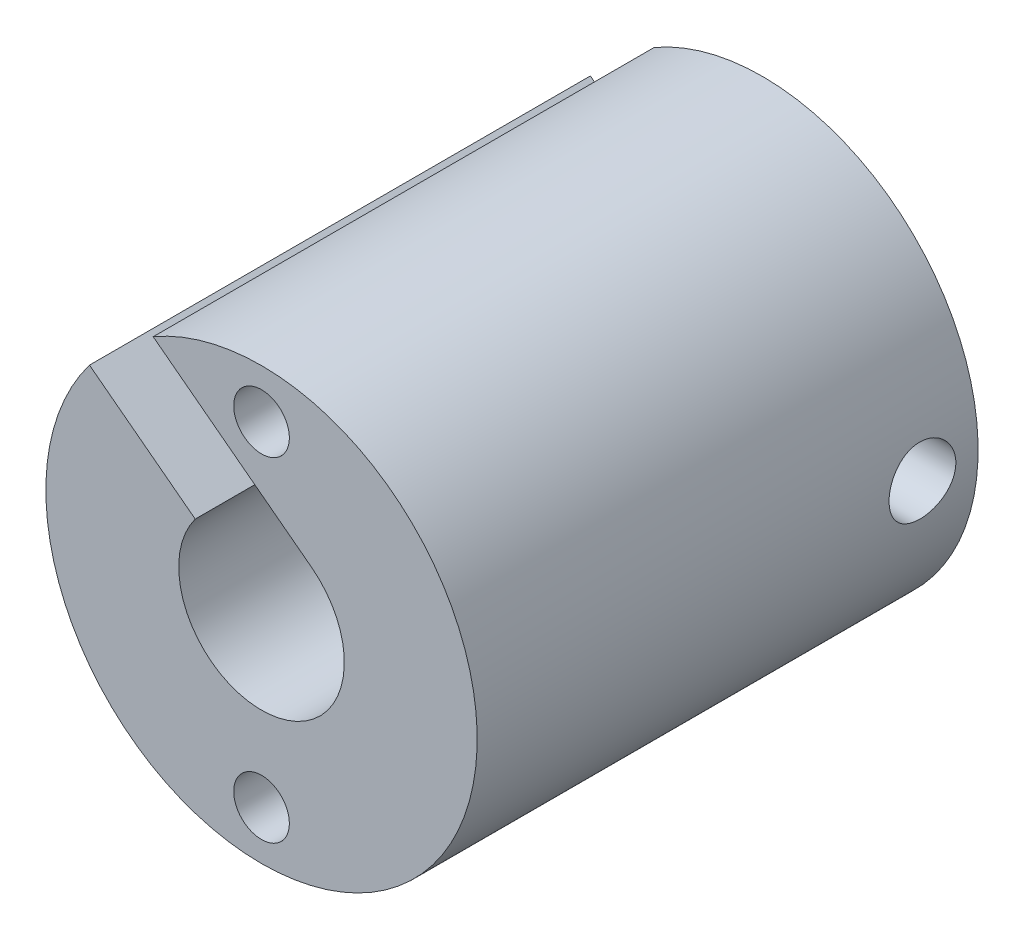
from build123d import *

# Parameters (mm, degrees)
SKETCH_1_R               = 7.75
SKETCH_1_R_2             = 2.975
SKETCH_1_R_3             = 1
EXTRUDE_1_DEPTH          = 18
SKETCH_2_R               = 1.2
CUT_EXTRUDE_1_DEPTH      = 8.75
CUT_EXTRUDE_1_DEPTH_BACK = 8.75
CUT_EXTRUDE_2_DEPTH      = 19.0000001


with BuildPart() as part:
    # 草图1 → 凸台-拉伸1 (new body)
    with BuildSketch(Plane.XY):
        Circle(SKETCH_1_R)
        Circle(SKETCH_1_R_2, mode=Mode.SUBTRACT)
        with Locations((0, 6)):
            Circle(SKETCH_1_R_3, mode=Mode.SUBTRACT)
        with Locations((0, -6)):
            Circle(SKETCH_1_R_3, mode=Mode.SUBTRACT)
    extrude(amount=EXTRUDE_1_DEPTH)

    # 草图2 → 切除-拉伸1 (cut, two sides)
    with BuildSketch(Plane(origin=(0, 0, 0), x_dir=(0, 0, -1), z_dir=(1, 0, 0))) as cut_extrude_1_sk:
        with Locations((-2, 0)):
            Circle(SKETCH_2_R)
    extrude(amount=CUT_EXTRUDE_1_DEPTH, mode=Mode.SUBTRACT)
    extrude(cut_extrude_1_sk.sketch, amount=-CUT_EXTRUDE_1_DEPTH_BACK, mode=Mode.SUBTRACT)

    # 草图3 → 切除-拉伸2 (cut, through all)
    with BuildSketch(Plane(origin=(0, 0, 0), x_dir=(-1, 0, 0), z_dir=(0, 0, -1))):
        Polygon((-1.801409312, 2.367604167), (3.893770807, 6.700824494), (6.182814137, 6.700824494), (6.182814137, 4.672826698), (2.382658463, 1.781449873), align=None)
    extrude(amount=-CUT_EXTRUDE_2_DEPTH, mode=Mode.SUBTRACT)


solid = part.part
